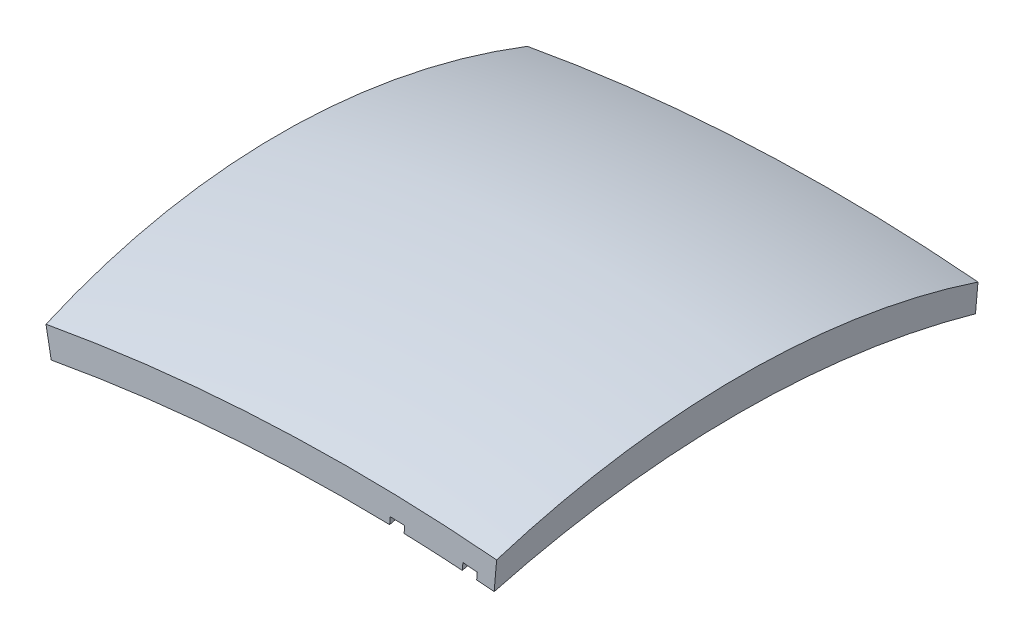
from build123d import *


with BuildPart() as part:
    # Sweep1: sweep along a path in Sketch1
    with BuildLine(Plane.XY) as sweep1_path:
        ThreePointArc((-890.285718, 339.546922), (-431.638177, 392.054842), (29.914282, 382.890989))
    # Sketch3 → Sweep1 (sweep)
    with BuildSketch(Plane(origin=(-890.285718, 339.546922, 0), x_dir=(0, 0, 1), z_dir=(-0.983681, -0.179923, 0))):
        with BuildLine():
            Line((0, 0), (0, 60))
            ThreePointArc((0, 60), (-500, 145.786438), (-1000, 60))
            Line((-1000, 60), (-1000, 0))
            ThreePointArc((-1000, 0), (-500, 73.913317), (0, 0))
        make_face()
    sweep(path=sweep1_path.line)

    # Cut-Sweep1: sweep along a path in Sketch19
    with BuildLine(Plane(origin=(-205.375388, 17.865632, 0), x_dir=(0, 0, -1), z_dir=(0.996238, -0.086663, 0))) as cut_sweep1_path:
        ThreePointArc((70, 403.60426), (34.897149, 394.191626), (0, 384.042894))
    # Sketch4 → Cut-Sweep1 (sweep, cut)
    with BuildSketch(Plane.XY):
        with BuildLine():
            Line((-185.86158, 409.845466), (-187.161523, 394.901901))
            ThreePointArc((-187.161523, 394.901901), (-172.395032, 385.472889), (-157.121749, 394.056733))
            Line((-157.121749, 394.056733), (-155.821806, 409.000299))
            ThreePointArc((-155.821806, 409.000299), (-170.840774, 409.455574), (-185.86158, 409.845466))
        make_face()
    cut_sweep1 = sweep(path=cut_sweep1_path.line, mode=Mode.SUBTRACT)

    # Cut-Sweep6: sweep along a path in Sketch24
    with BuildLine(Plane(origin=(-54.770437, 4.764487, 0), x_dir=(0, 0, -1), z_dir=(0.996238, -0.086663, 0))) as cut_sweep6_path:
        ThreePointArc((70, 403.60426), (34.897149, 394.191626), (0, 384.042894))
    # Sketch22 → Cut-Sweep6 (sweep, cut)
    with BuildSketch(Plane.XY):
        with BuildLine():
            Line((-6.365403, 385.85431), (-5.10418, 400.352779))
            Line((-5.10418, 400.352779), (-34.991311, 402.952665))
            Line((-34.991311, 402.952665), (-36.291253, 388.009099))
            ThreePointArc((-36.291253, 388.009099), (-21.81537, 380.167646), (-6.365403, 385.85431))
        make_face()
    cut_sweep6 = sweep(path=cut_sweep6_path.line, mode=Mode.SUBTRACT)

    # Mirror1: Cut-Sweep1, Cut-Sweep6 across plane
    add(cut_sweep1.mirror(Plane.XY.offset(-500)), mode=Mode.SUBTRACT)
    add(cut_sweep6.mirror(Plane.XY.offset(-500)), mode=Mode.SUBTRACT)


solid = part.part
